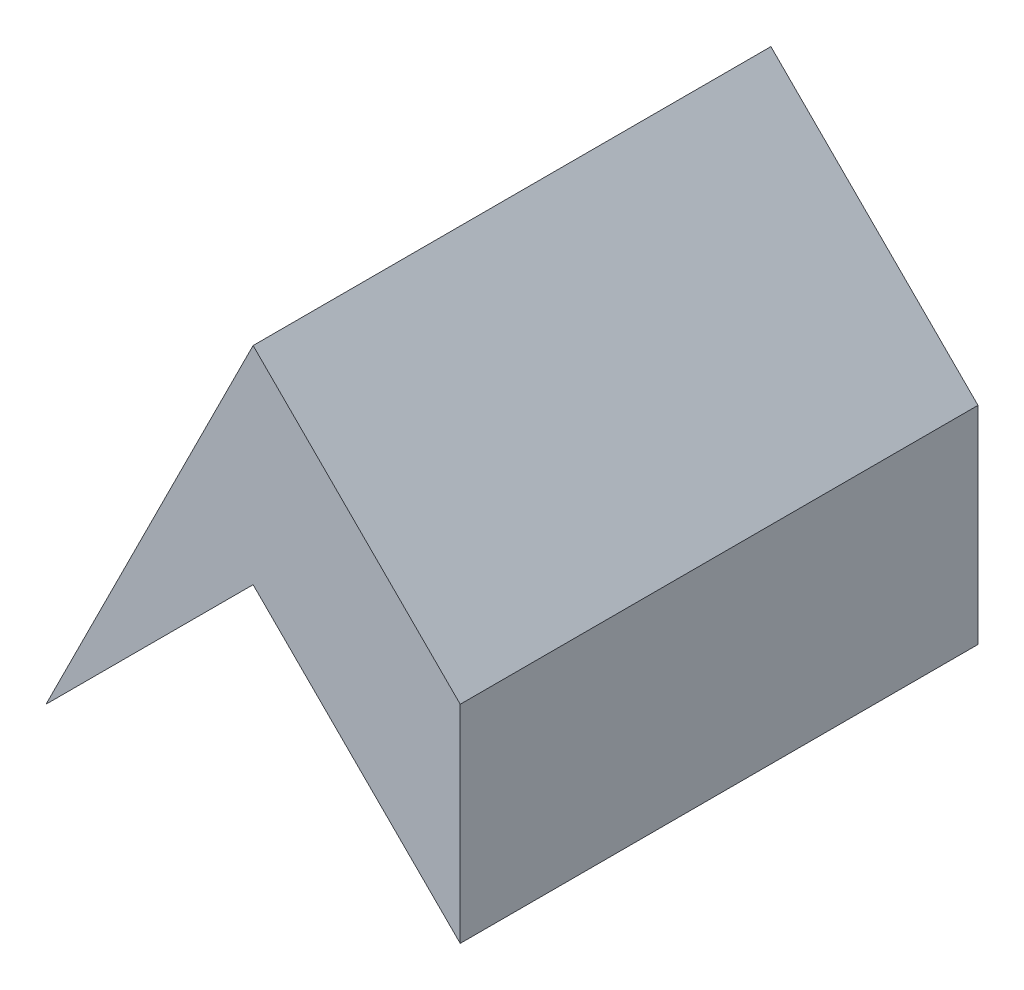
from build123d import *

# Parameters (mm, degrees)
BOSS_EXTRUDE1_DEPTH = 25


with BuildPart() as part:
    # Sketch1 → Boss-Extrude1 (new body)
    with BuildSketch(Plane.XY):
        Polygon((-20, 0), (-10, 20), (0, 10), (0, 0), (-10, 10), align=None)
    extrude(amount=BOSS_EXTRUDE1_DEPTH)


solid = part.part
